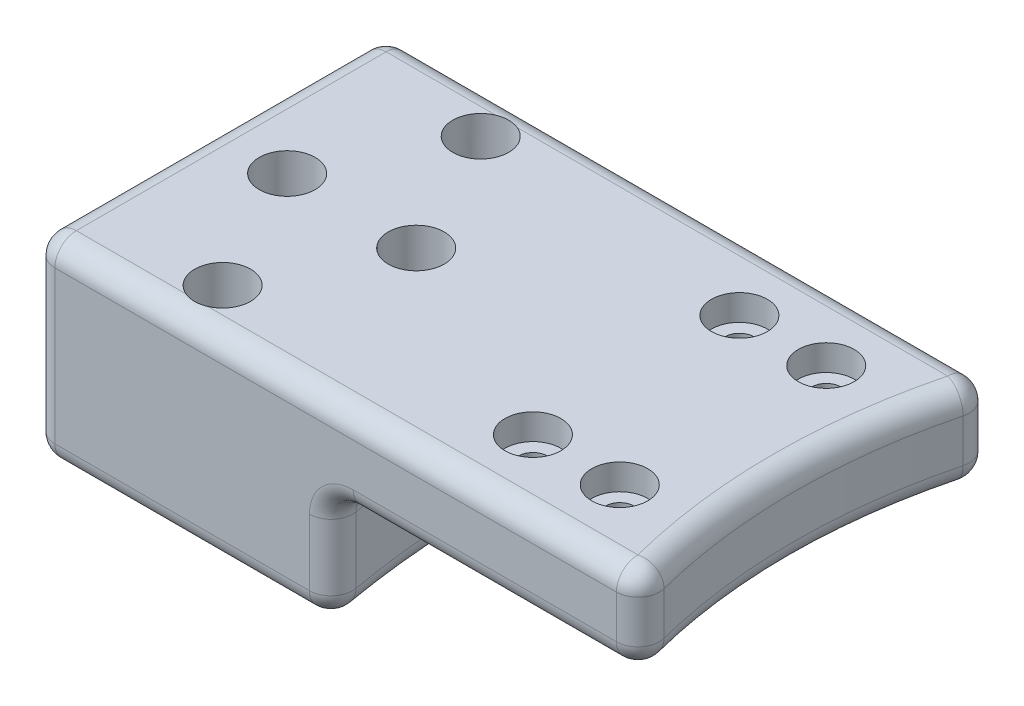
from build123d import *

# Parameters (mm, degrees)
BOSS_EXTRUDE1_DEPTH            = 20.5
SKETCH2_R                      = 70
CUT_EXTRUDE1_DEPTH             = 41
SKETCH3_R                      = 100
CUT_EXTRUDE2_DEPTH             = 41
FILLET1_R                      = 2.5
CBORE_FOR_M3_SHCS1_D           = 3.4
CBORE_FOR_M3_SHCS1_DEPTH       = 45
CBORE_FOR_M3_SHCS1_CBORE_D     = 6.5
CBORE_FOR_M3_SHCS1_CBORE_DEPTH = 5
CBORE_FOR_M3_SHCS1_TIP         = 1.021463052
CBORE_FOR_M3_SHCS2_D           = 3.4
CBORE_FOR_M3_SHCS2_DEPTH       = 45
CBORE_FOR_M3_SHCS2_CBORE_D     = 6.5
CBORE_FOR_M3_SHCS2_CBORE_DEPTH = 3
CBORE_FOR_M3_SHCS2_TIP         = 1.021463052


with BuildPart() as part:
    # Sketch1 → Boss-Extrude1 (new body, symmetric)
    with BuildSketch(Plane.XY):
        Polygon((-70, 0), (-105, 0), (-105, -12.7), (-143, -12.7), (-143, 10), (-70, 10), align=None)
    extrude(amount=BOSS_EXTRUDE1_DEPTH, both=True)

    # Sketch2 → Cut-Extrude1 (cut)
    with BuildSketch(Plane(origin=(0, 10, 0), x_dir=(1, 0, 0), z_dir=(0, 1, 0))):
        with Locations((-5, 0)):
            Circle(SKETCH2_R)
    extrude(amount=-CUT_EXTRUDE1_DEPTH, mode=Mode.SUBTRACT)

    # Sketch3 → Cut-Extrude2 (cut)
    with BuildSketch(Plane(origin=(0, 0, 0), x_dir=(1, 0, 0), z_dir=(0, 1, 0))):
        with Locations((-10, 0)):
            Circle(SKETCH3_R)
    extrude(amount=-CUT_EXTRUDE2_DEPTH, mode=Mode.SUBTRACT)

    # Fillet1
    fillet1_edges = [part.edges().sort_by_distance(p)[0] for p in [
        (-143, -12.7, 0),
        (-143, 10, 0),
        (-143, -1.35, 20.5),
        (-125.438098655, -12.7, 20.5),
        (-107.465467276, 10, -20.5),
        (-71.930934552, 5, -20.5),
        (-107.465467276, 10, 20.5),
        (-75, 0, 0),
        (-71.930934552, 5, 20.5),
        (-75, 10, 0),
        (-89.903565931, 0, 20.5),
        (-107.876197311, -6.35, -20.5),
        (-110, -12.7, 0),
        (-107.876197311, -6.35, 20.5),
        (-110, 0, 0),
        (-89.903565931, 0, -20.5),
        (-125.438098655, -12.7, -20.5),
        (-143, -1.35, -20.5),
    ]]
    fillet(fillet1_edges, radius=FILLET1_R)

    # CBORE for M3 SHCS1
    with Locations(Plane(origin=(0, 10, 0), x_dir=(1, 0, 0), z_dir=(0, 1, 0))):
        with Locations((-134, 0), (-119, 0), (-126.5, 15), (-126.5, -15)):
            CounterBoreHole(CBORE_FOR_M3_SHCS1_D / 2, CBORE_FOR_M3_SHCS1_CBORE_D / 2, CBORE_FOR_M3_SHCS1_CBORE_DEPTH, depth=CBORE_FOR_M3_SHCS1_DEPTH)
            with Locations((0, 0, -(CBORE_FOR_M3_SHCS1_DEPTH + CBORE_FOR_M3_SHCS1_TIP / 2))):  # 118° drill point
                Cone(0, CBORE_FOR_M3_SHCS1_D / 2, CBORE_FOR_M3_SHCS1_TIP, mode=Mode.SUBTRACT)

    # CBORE for M3 SHCS2
    with Locations(Plane(origin=(0, 10, 0), x_dir=(1, 0, 0), z_dir=(0, 1, 0))):
        with Locations((-93.432542511, 12), (-93.432542511, -12), (-83.340506358, 12), (-83.340506358, -12)):
            CounterBoreHole(CBORE_FOR_M3_SHCS2_D / 2, CBORE_FOR_M3_SHCS2_CBORE_D / 2, CBORE_FOR_M3_SHCS2_CBORE_DEPTH, depth=CBORE_FOR_M3_SHCS2_DEPTH)
            with Locations((0, 0, -(CBORE_FOR_M3_SHCS2_DEPTH + CBORE_FOR_M3_SHCS2_TIP / 2))):  # 118° drill point
                Cone(0, CBORE_FOR_M3_SHCS2_D / 2, CBORE_FOR_M3_SHCS2_TIP, mode=Mode.SUBTRACT)


solid = part.part
